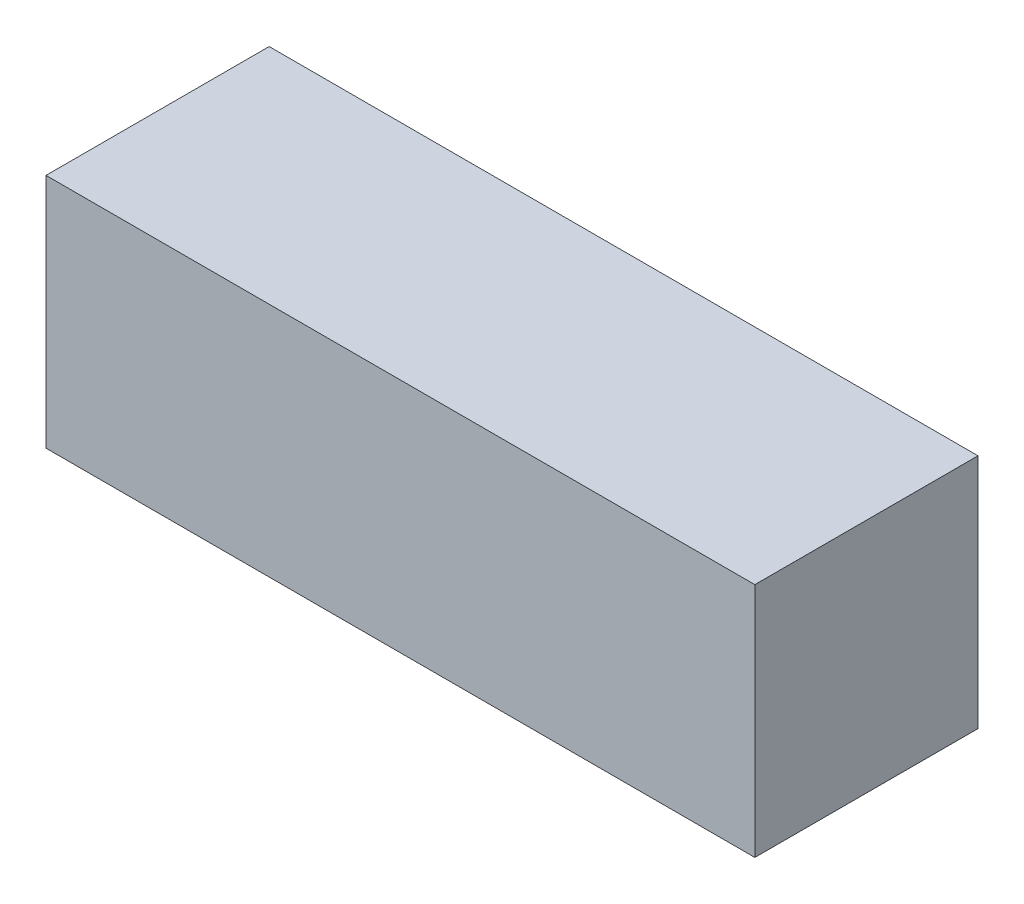
from build123d import *

# Parameters (mm, degrees)
SKETCH1_W           = 54
SKETCH1_H           = 17
BOSS_EXTRUDE1_DEPTH = 18


with BuildPart() as part:
    # Sketch1 → Boss-Extrude1 (new body)
    with BuildSketch(Plane(origin=(0, 0, 0), x_dir=(1, 0, 0), z_dir=(0, 1, 0))):
        Rectangle(SKETCH1_W, SKETCH1_H)
    extrude(amount=BOSS_EXTRUDE1_DEPTH)


solid = part.part
